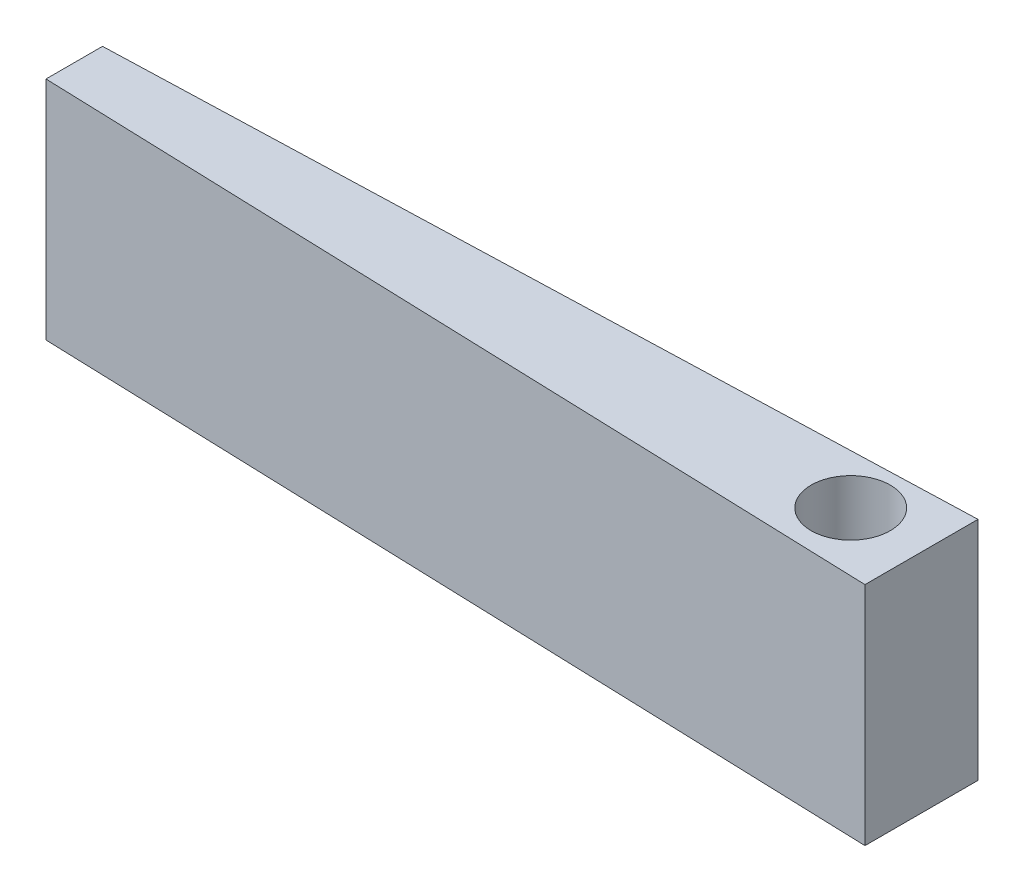
from build123d import *

# Parameters (mm, degrees)
BOSS_EXTRUDE1_DEPTH = 40
SKETCH2_R           = 7
CUT_EXTRUDE1_DEPTH  = 25


with BuildPart() as part:
    # Sketch1 → Boss-Extrude1 (new body)
    with BuildSketch(Plane(origin=(0, 0, 0), x_dir=(1, 0, 0), z_dir=(0, 1, 0))):
        Polygon((-46.903241084, -0.468259604), (-46.903241084, -10.468259604), (103.014291308, -15.494982846), (103.014291308, 4.505017154), align=None)
    extrude(amount=BOSS_EXTRUDE1_DEPTH)

    # Sketch2 → Cut-Extrude1 (cut)
    with BuildSketch(Plane(origin=(0, 40, 0), x_dir=(1, 0, 0), z_dir=(0, 1, 0))):
        with Locations((90, -5)):
            Circle(SKETCH2_R)
    extrude(amount=-CUT_EXTRUDE1_DEPTH, mode=Mode.SUBTRACT)


solid = part.part
